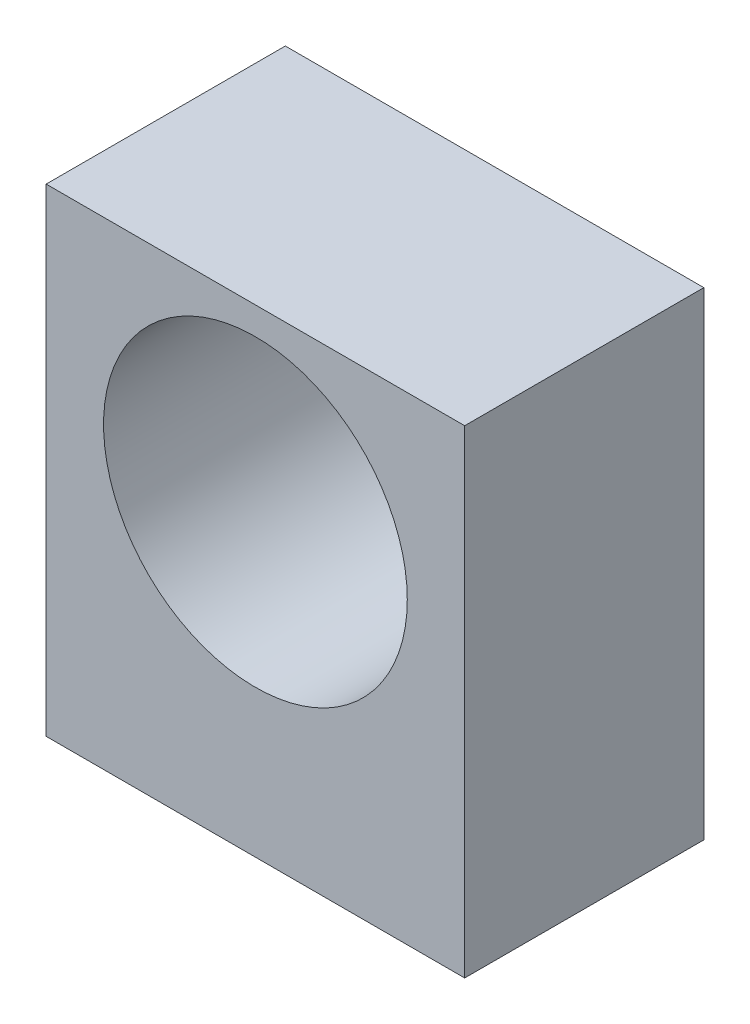
from build123d import *

# Parameters (mm, degrees)
SKETCH1_W           = 35
SKETCH1_H           = 20
BOSS_EXTRUDE1_DEPTH = 40
SKETCH2_R           = 12.7
CUT_EXTRUDE1_DEPTH  = 21
SKETCH3_R           = 1.75
CUT_EXTRUDE2_DEPTH  = 10


with BuildPart() as part:
    # Sketch1 → Boss-Extrude1 (new body)
    with BuildSketch(Plane(origin=(0, 0, 0), x_dir=(1, 0, 0), z_dir=(0, 1, 0))):
        with Locations((1.164675851, -0.855170824)):
            Rectangle(SKETCH1_W, SKETCH1_H)
    extrude(amount=BOSS_EXTRUDE1_DEPTH)

    # Sketch2 → Cut-Extrude1 (cut, through all)
    with BuildSketch(Plane.XY.offset(10.855170824)):
        with Locations((1.164675851, 25)):
            Circle(SKETCH2_R)
    extrude(amount=-CUT_EXTRUDE1_DEPTH, mode=Mode.SUBTRACT)

    # Sketch3 → Cut-Extrude2 (cut)
    with BuildSketch(Plane.XZ):
        with Locations((-8.335324149, 0.855170824)):
            Circle(SKETCH3_R)
        with Locations((10.664675851, 0.855170824)):
            Circle(SKETCH3_R)
    extrude(amount=-CUT_EXTRUDE2_DEPTH, mode=Mode.SUBTRACT)


solid = part.part
